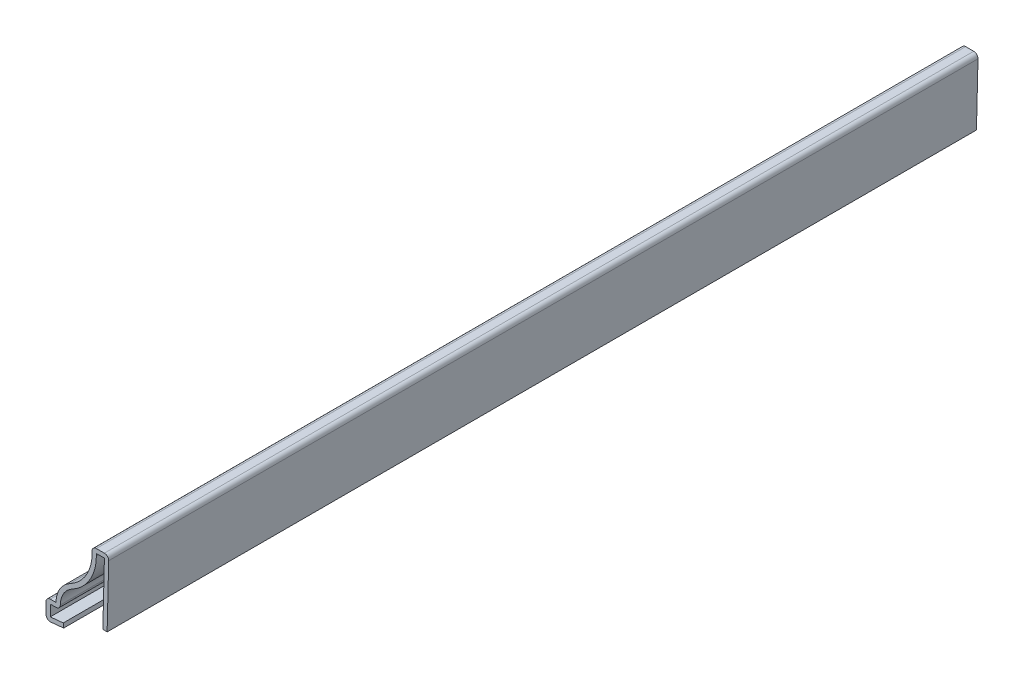
from build123d import *

# Parameters (mm, degrees)
EXTRUDE_THIN1_DEPTH = 206.375
FILLET1_R           = 1.016


with BuildPart() as part:
    # Sketch2 → Extrude-Thin1 (new body)
    with BuildSketch(Plane.XY):
        with BuildLine():
            Line((-10.715625, 0.396875), (-14.906625, 0))
            Line((-14.906625, 0), (-14.906625, 4.7625))
            Line((-14.906625, 4.7625), (-12.525255186, 4.7625))
            ThreePointArc((-12.525255186, 4.7625), (-11.617011589, 7.996272283), (-9.186204268, 10.314324348))
            ThreePointArc((-9.186204268, 10.314324348), (-5.372401066, 13.962420562), (-3.96875, 19.05))
            Line((-3.96875, 19.05), (-3.96875, 20.6375))
            Line((-3.96875, 20.6375), (0, 20.6375))
            Line((0, 20.6375), (-0.396875, 4.7625))
            Line((-0.396875, 4.7625), (-1.412557649, 4.787892066))
            Line((-1.412557649, 4.787892066), (-1.04171745, 19.6215))
            Line((-1.04171745, 19.6215), (-2.95275, 19.6215))
            Line((-2.95275, 19.6215), (-2.95275, 19.05))
            ThreePointArc((-2.95275, 19.05), (-4.500134936, 13.441452428), (-8.704471585, 9.419791161))
            ThreePointArc((-8.704471585, 9.419791161), (-10.986912369, 7.025809056), (-11.419137272, 3.7465))
            Line((-11.419137272, 3.7465), (-13.890625, 3.7465))
            Line((-13.890625, 3.7465), (-13.890625, 1.116757452))
            Line((-13.890625, 1.116757452), (-10.811408609, 1.408349913))
            Line((-10.811408609, 1.408349913), (-10.715625, 0.396875))
        make_face()
    extrude(amount=-EXTRUDE_THIN1_DEPTH)

    # Fillet1
    fillet1_edges = [part.edges().sort_by_distance(p)[0] for p in [
        (-11.419137272, 3.7465, -103.1875),
        (-14.906625, 0, -103.1875),
        (-14.906625, 4.7625, -103.1875),
        (-3.96875, 20.6375, -103.1875),
        (0, 20.6375, -103.1875),
    ]]
    fillet(fillet1_edges, radius=FILLET1_R)


solid = part.part
